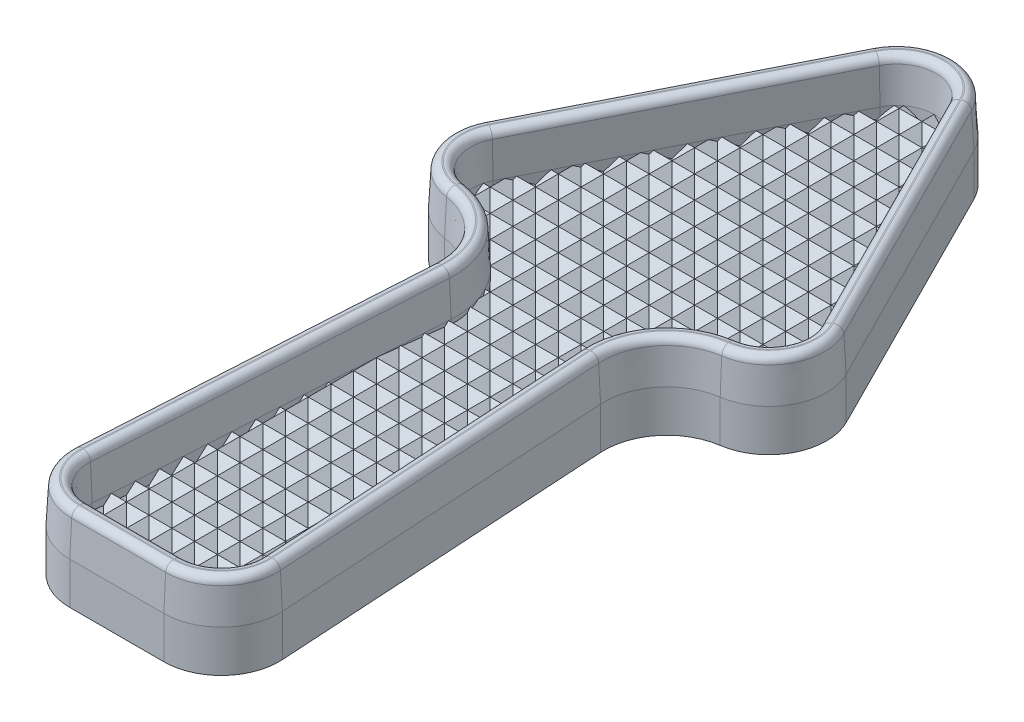
from build123d import *

# Parameters (mm, degrees)
SKETCH2_W           = 31.75
SKETCH2_H           = 63.5
BOSS_EXTRUDE1_DEPTH = 2.3368
BOSS_EXTRUDE2_DEPTH = 31.75
BOSS_EXTRUDE3_DEPTH = 15.875
LPATTERN1_COUNT     = 19
LPATTERN1_PITCH     = 1.7235678
LPATTERN1_COL_COUNT = 19
LPATTERN1_COL_PITCH = 1.7235678
LPATTERN2_COUNT     = 10
LPATTERN2_PITCH     = 1.7235678
LPATTERN2_COL_COUNT = 10
LPATTERN2_COL_PITCH = 1.7235678
SKETCH6_OUTSIDE_W   = 49.164
SKETCH6_OUTSIDE_H   = 80.554
CUT_EXTRUDE1_DEPTH  = 15.875
EXTRUDE_THIN1_DEPTH = 3.175
BOSS_EXTRUDE4_DEPTH = 3.175
BOSS_EXTRUDE4_DRAFT = 3
FILLET1_R           = 0.5842


with BuildPart() as part:
    # Sketch2 → Boss-Extrude1 (new body)
    with BuildSketch(Plane(origin=(0, 0, 0), x_dir=(1, 0, 0), z_dir=(0, 1, 0))):
        Rectangle(SKETCH2_W, SKETCH2_H)
    extrude(amount=BOSS_EXTRUDE1_DEPTH)

    # Sketch3 → Boss-Extrude2 (add, symmetric)
    with BuildSketch(Plane.XY):
        Polygon((0, 3.175), (-0.861695, 2.313305), (0.861695, 2.313305), align=None)
    boss_extrude2 = extrude(amount=BOSS_EXTRUDE2_DEPTH, both=True)

    # Sketch4 → Boss-Extrude3 (add, symmetric)
    with BuildSketch(Plane(origin=(0, 0, 0), x_dir=(0, 0, -1), z_dir=(1, 0, 0))):
        Polygon((0, 3.175), (1.04506973, 2.12993027), (-1.04506973, 2.12993027), align=None)
    boss_extrude3 = extrude(amount=BOSS_EXTRUDE3_DEPTH, both=True)

    # LPattern1: Boss-Extrude3 ×19
    with Locations(*[(0, 0, -i * LPATTERN1_PITCH) for i in range(1, LPATTERN1_COUNT)]):
        add(boss_extrude3)

    # LPattern1 col: Boss-Extrude3 ×19
    with Locations(*[(0, 0, i * LPATTERN1_COL_PITCH) for i in range(1, LPATTERN1_COL_COUNT)]):
        add(boss_extrude3)

    # LPattern2: Boss-Extrude2 ×10
    with Locations(*[(-i * LPATTERN2_PITCH, 0, 0) for i in range(1, LPATTERN2_COUNT)]):
        add(boss_extrude2)

    # LPattern2 col: Boss-Extrude2 ×10
    with Locations(*[(i * LPATTERN2_COL_PITCH, 0, 0) for i in range(1, LPATTERN2_COL_COUNT)]):
        add(boss_extrude2)

    # Sketch6 outside → Cut-Extrude1 (cut)
    with BuildSketch(Plane(origin=(0, 0, 0), x_dir=(1, 0, 0), z_dir=(0, 1, 0))):
        Rectangle(SKETCH6_OUTSIDE_W, SKETCH6_OUTSIDE_H)
        with BuildLine():
            Line((6.380220169, -1.448611773), (7.921789131, -27.122717859))
            ThreePointArc((7.921789131, -27.122717859), (6.742139194, -30.377398946), (3.564012498, -31.75))
            Line((3.564012498, -31.75), (-3.564012498, -31.75))
            ThreePointArc((-3.564012498, -31.75), (-6.742139194, -30.377398946), (-7.921789131, -27.122717859))
            Line((-7.921789131, -27.122717859), (-6.380220169, -1.448611773))
            ThreePointArc((-6.380220169, -1.448611773), (-7.441604295, 1.844564262), (-10.45196702, 3.550219834))
            ThreePointArc((-10.45196702, 3.550219834), (-13.69835518, 5.853800694), (-13.72575986, 9.834349633))
            Line((-13.72575986, 9.834349633), (-3.89913486, 29.347899633))
            ThreePointArc((-3.89913486, 29.347899633), (0, 31.75), (3.89913486, 29.347899633))
            Line((3.89913486, 29.347899633), (13.72575986, 9.834349633))
            ThreePointArc((13.72575986, 9.834349633), (13.69835518, 5.853800694), (10.45196702, 3.550219834))
            ThreePointArc((10.45196702, 3.550219834), (7.441604295, 1.844564262), (6.380220169, -1.448611773))
        make_face(mode=Mode.SUBTRACT)
    extrude(amount=CUT_EXTRUDE1_DEPTH, mode=Mode.SUBTRACT)

    # Sketch7 → Extrude-Thin1 (add)
    with BuildSketch(Plane.XZ):
        with BuildLine():
            Line((3.564012498, 31.75), (-3.564012498, 31.75))
            ThreePointArc((-3.564012498, 31.75), (-6.742139194, 30.377398946), (-7.921789131, 27.122717859))
            Line((-7.921789131, 27.122717859), (-6.380220169, 1.448611773))
            ThreePointArc((-6.380220169, 1.448611773), (-7.441604295, -1.844564262), (-10.45196702, -3.550219834))
            ThreePointArc((-10.45196702, -3.550219834), (-13.69835518, -5.853800694), (-13.72575986, -9.834349633))
            Line((-13.72575986, -9.834349633), (-3.89913486, -29.347899633))
            ThreePointArc((-3.89913486, -29.347899633), (0, -31.75), (3.89913486, -29.347899633))
            Line((3.89913486, -29.347899633), (13.72575986, -9.834349633))
            ThreePointArc((13.72575986, -9.834349633), (13.69835518, -5.853800694), (10.45196702, -3.550219834))
            ThreePointArc((10.45196702, -3.550219834), (7.441604295, -1.844564262), (6.380220169, 1.448611773))
            Line((6.380220169, 1.448611773), (7.921789131, 27.122717859))
            ThreePointArc((7.921789131, 27.122717859), (6.742139194, 30.377398946), (3.564012498, 31.75))
        make_face()
        with BuildLine():
            Line((3.564012498, 30.226), (-3.564012498, 30.226))
            ThreePointArc((-3.564012498, 30.226), (-5.632684057, 29.332561496), (-6.400528924, 27.214059988))
            Line((-6.400528924, 27.214059988), (-4.858959963, 1.539953903))
            ThreePointArc((-4.858959963, 1.539953903), (-6.259987009, -2.807038464), (-10.233665806, -5.058503819))
            ThreePointArc((-10.233665806, -5.058503819), (-12.346769372, -6.557925543), (-12.364607327, -9.148901034))
            Line((-12.364607327, -9.148901034), (-2.537982327, -28.662451034))
            ThreePointArc((-2.537982327, -28.662451034), (0, -30.226), (2.537982327, -28.662451034))
            Line((2.537982327, -28.662451034), (12.364607327, -9.148901034))
            ThreePointArc((12.364607327, -9.148901034), (12.346769372, -6.557925543), (10.233665806, -5.058503819))
            ThreePointArc((10.233665806, -5.058503819), (6.259987009, -2.807038464), (4.858959963, 1.539953903))
            Line((4.858959963, 1.539953903), (6.400528924, 27.214059988))
            ThreePointArc((6.400528924, 27.214059988), (5.632684057, 29.332561496), (3.564012498, 30.226))
        make_face(mode=Mode.SUBTRACT)
    extrude(amount=-EXTRUDE_THIN1_DEPTH)


with BuildPart() as boss_extrude4_tool:
    # Sketch8 → Boss-Extrude4 (with draft: the straight prism first)
    with BuildSketch(Plane(origin=(0, 3.175, 0), x_dir=(1, 0, 0), z_dir=(0, 1, 0))):
        with BuildLine():
            Line((-6.380220169, -1.448611773), (-7.921789131, -27.122717859))
            ThreePointArc((-7.921789131, -27.122717859), (-6.742139194, -30.377398946), (-3.564012498, -31.75))
            Line((-3.564012498, -31.75), (3.564012498, -31.75))
            ThreePointArc((3.564012498, -31.75), (6.742139194, -30.377398946), (7.921789131, -27.122717859))
            Line((7.921789131, -27.122717859), (6.380220169, -1.448611773))
            ThreePointArc((6.380220169, -1.448611773), (7.441604295, 1.844564262), (10.45196702, 3.550219834))
            ThreePointArc((10.45196702, 3.550219834), (13.69835518, 5.853800694), (13.72575986, 9.834349633))
            Line((13.72575986, 9.834349633), (3.89913486, 29.347899633))
            ThreePointArc((3.89913486, 29.347899633), (0, 31.75), (-3.89913486, 29.347899633))
            Line((-3.89913486, 29.347899633), (-13.72575986, 9.834349633))
            ThreePointArc((-13.72575986, 9.834349633), (-13.69835518, 5.853800694), (-10.45196702, 3.550219834))
            ThreePointArc((-10.45196702, 3.550219834), (-7.441604295, 1.844564262), (-6.380220169, -1.448611773))
        make_face()
        with BuildLine():
            Line((12.364607327, 9.148901034), (2.537982327, 28.662451034))
            ThreePointArc((2.537982327, 28.662451034), (0, 30.226), (-2.537982327, 28.662451034))
            Line((-2.537982327, 28.662451034), (-12.364607327, 9.148901034))
            ThreePointArc((-12.364607327, 9.148901034), (-12.346769372, 6.557925543), (-10.233665806, 5.058503819))
            ThreePointArc((-10.233665806, 5.058503819), (-6.259987009, 2.807038464), (-4.858959963, -1.539953903))
            Line((-4.858959963, -1.539953903), (-6.400528924, -27.214059988))
            ThreePointArc((-6.400528924, -27.214059988), (-5.632684057, -29.332561496), (-3.564012498, -30.226))
            Line((-3.564012498, -30.226), (3.564012498, -30.226))
            ThreePointArc((3.564012498, -30.226), (5.632684057, -29.332561496), (6.400528924, -27.214059988))
            Line((6.400528924, -27.214059988), (4.858959963, -1.539953903))
            ThreePointArc((4.858959963, -1.539953903), (6.259987009, 2.807038464), (10.233665806, 5.058503819))
            ThreePointArc((10.233665806, 5.058503819), (12.346769372, 6.557925543), (12.364607327, 9.148901034))
        make_face(mode=Mode.SUBTRACT)
    extrude(amount=BOSS_EXTRUDE4_DEPTH)
    # Boss-Extrude4: the draft: its side faces are tilted about the plane it starts from
    boss_extrude4_sides = [boss_extrude4_tool.faces().sort_by_distance(p)[0] for p in [
        (-7.15100465, 4.7625, 14.285664816),
        (-6.742139194, 4.7625, 30.377398946),
        (0, 4.7625, 31.75),
        (6.742139194, 4.7625, 30.377398946),
        (7.15100465, 4.7625, 14.285664816),
        (7.441604295, 4.7625, -1.844564262),
        (13.69835518, 4.7625, -5.853800694),
        (8.81244736, 4.7625, -19.591124633),
        (0, 4.7625, -31.75),
        (-8.81244736, 4.7625, -19.591124633),
        (-13.69835518, 4.7625, -5.853800694),
        (-7.441604295, 4.7625, -1.844564262),
        (6.259987009, 4.7625, -2.807038464),
        (5.629744443, 4.7625, 14.377006945),
        (5.632684057, 4.7625, 29.332561496),
        (0, 4.7625, 30.226),
        (-5.632684057, 4.7625, 29.332561496),
        (-5.629744443, 4.7625, 14.377006945),
        (-6.259987009, 4.7625, -2.807038464),
        (-12.346769372, 4.7625, -6.557925543),
        (-7.451294827, 4.7625, -18.905676034),
        (0, 4.7625, -30.226),
        (7.451294827, 4.7625, -18.905676034),
        (12.346769372, 4.7625, -6.557925543),
    ]]
    draft(boss_extrude4_sides, Plane(origin=(0, 3.175, 0), x_dir=(1, 0, 0), z_dir=(0, 1, 0)), BOSS_EXTRUDE4_DRAFT)


with BuildPart() as part_1:
    add(part.part)

    # Boss-Extrude4: add boss_extrude4_tool
    add(boss_extrude4_tool.part)

    # Fillet1
    fillet1_edges = [part_1.edges().sort_by_distance(p)[0] for p in [
        (-7.312591925, 6.35, -1.949649961),
        (-6.984909089, 6.35, 14.295637812),
        (-6.621005694, 6.35, 30.263320591),
        (0, 6.35, 31.583605301),
        (6.621005694, 6.35, 30.263320591),
        (6.984909089, 6.35, 14.295637812),
        (7.312591925, 6.35, -1.949649961),
        (13.550785158, 6.35, -5.930679068),
        (8.663832815, 6.35, -19.516285385),
        (0, 6.35, -31.583605301),
        (-8.663832815, 6.35, -19.516285385),
        (-13.550785158, 6.35, -5.930679068),
        (12.494339394, 6.35, -6.481047168),
        (7.599909372, 6.35, -18.980515281),
        (0, 6.35, -30.392394699),
        (-7.599909372, 6.35, -18.980515281),
        (-12.494339394, 6.35, -6.481047168),
        (-6.38899938, 6.35, -2.701952765),
        (-5.795840004, 6.35, 14.367033949),
        (-5.753817557, 6.35, 29.446639851),
        (0, 6.35, 30.392394699),
        (5.753817557, 6.35, 29.446639851),
        (5.795840004, 6.35, 14.367033949),
        (6.38899938, 6.35, -2.701952765),
    ]]
    fillet(fillet1_edges, radius=FILLET1_R)


solid = part_1.part
